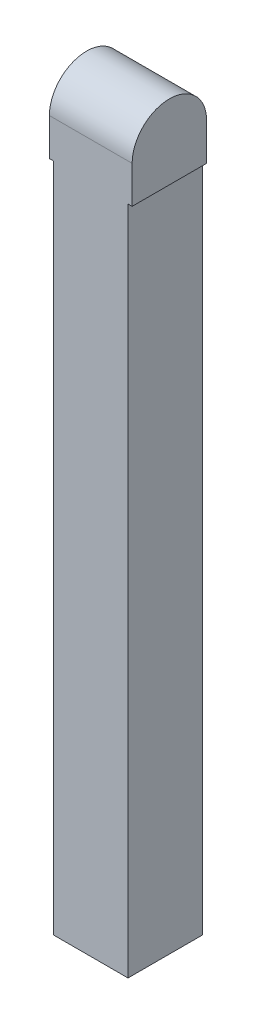
from build123d import *

# Parameters (mm, degrees)
SKETCH_1_W          = 18
SKETCH_1_H          = 18
EXTRUDE_1_DEPTH     = 160
SKETCH_2_W          = 18
SKETCH_2_H          = 18
EXTRUDE_2_DEPTH     = 2
SKETCH_3_W          = 20
SKETCH_3_H          = 18
EXTRUDE_4_DEPTH     = 18
CUT_EXTRUDE_1_DEPTH = 21


with BuildPart() as part:
    # 草图1 → 凸台-拉伸1 (new body)
    with BuildSketch(Plane(origin=(0, 0, 0), x_dir=(1, 0, 0), z_dir=(0, 1, 0))):
        Rectangle(SKETCH_1_W, SKETCH_1_H)
    extrude(amount=EXTRUDE_1_DEPTH)

    # 草图2 → 凸台-拉伸2 (add)
    with BuildSketch(Plane(origin=(0, 160, 0), x_dir=(1, 0, 0), z_dir=(0, 1, 0))):
        Rectangle(SKETCH_2_W, SKETCH_2_H)
    extrude(amount=EXTRUDE_2_DEPTH)

    # 草图3 → 凸台-拉伸4 (add)
    with BuildSketch(Plane(origin=(0, 162, 0), x_dir=(1, 0, 0), z_dir=(0, 1, 0))):
        Rectangle(SKETCH_3_W, SKETCH_3_H)
    extrude(amount=EXTRUDE_4_DEPTH)

    # 草图4 → 切除-拉伸1 (cut, through all)
    with BuildSketch(Plane.ZY.offset(10)):
        with BuildLine():
            Line((-9, 171), (-9, 185))
            Line((-9, 185), (9, 185))
            Line((9, 185), (9, 171))
            ThreePointArc((9, 171), (0, 180), (-9, 171))
        make_face()
    extrude(amount=-CUT_EXTRUDE_1_DEPTH, mode=Mode.SUBTRACT)


solid = part.part
